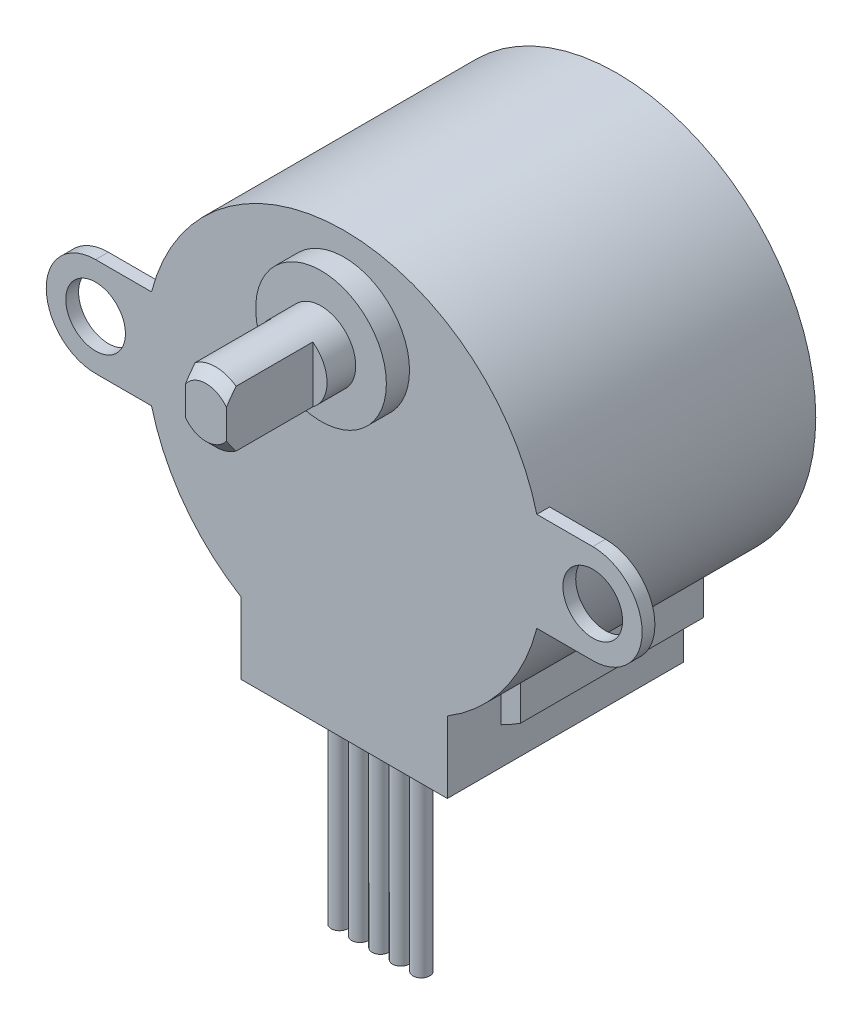
from build123d import *

# Parameters (mm, degrees)
SKETCH1_R           = 14
BOSS_EXTRUDE1_DEPTH = 19.2
BOSS_EXTRUDE2_DEPTH = 16.64
BOSS_EXTRUDE3_DEPTH = 12.87
SKETCH4_R           = 0.585
BOSS_EXTRUDE4_DEPTH = 14
SKETCH5_R           = 4.6
BOSS_EXTRUDE5_DEPTH = 1.63
SKETCH6_R           = 2.445
BOSS_EXTRUDE6_DEPTH = 8.1
CUT_EXTRUDE1_DEPTH  = 6.08
CHAMFER1_SIZE       = 0.68
SKETCH8_R           = 2.1
BOSS_EXTRUDE7_DEPTH = 0.9


with BuildPart() as part:
    # Sketch1 → Boss-Extrude1 (new body)
    with BuildSketch(Plane.XY):
        Circle(SKETCH1_R)
    extrude(amount=-BOSS_EXTRUDE1_DEPTH)

    # Sketch2 → Boss-Extrude2 (add)
    with BuildSketch(Plane.XY):
        with BuildLine():
            Line((-7.265, -11.967446469), (-7.265, -17))
            Line((-7.265, -17), (7.265, -17))
            Line((7.265, -17), (7.265, -11.967446469))
            ThreePointArc((7.265, -11.967446469), (0, -14), (-7.265, -11.967446469))
        make_face()
    extrude(amount=-BOSS_EXTRUDE2_DEPTH)

    # Sketch3 → Boss-Extrude3 (add)
    with BuildSketch(Plane(origin=(0, 0, -16.64), x_dir=(-1, 0, 0), z_dir=(0, 0, -1))):
        with BuildLine():
            Line((7.265, -14.390072098), (7.265, -11.967446469))
            ThreePointArc((7.265, -11.967446469), (7.969331726, -11.510419273), (8.645, -11.011992327))
            Line((8.645, -11.011992327), (8.645, -13.605821364))
            ThreePointArc((8.645, -13.605821364), (7.964658643, -14.014942479), (7.265, -14.390072098))
        make_face()
        with BuildLine():
            Line((-7.265, -11.967446469), (-7.265, -14.390072098))
            ThreePointArc((-7.265, -14.390072098), (-7.964658643, -14.014942479), (-8.645, -13.605821364))
            Line((-8.645, -13.605821364), (-8.645, -11.011992327))
            ThreePointArc((-8.645, -11.011992327), (-7.969331726, -11.510419273), (-7.265, -11.967446469))
        make_face()
    extrude(amount=-BOSS_EXTRUDE3_DEPTH)

    # Sketch4 → Boss-Extrude4 (add)
    with BuildSketch(Plane.XZ.offset(17)):
        with Locations((-2.88, -2.555)):
            Circle(SKETCH4_R)
        with Locations((-1.44, -2.555)):
            Circle(SKETCH4_R)
        with Locations((0, -2.555)):
            Circle(SKETCH4_R)
        with Locations((1.44, -2.555)):
            Circle(SKETCH4_R)
        with Locations((2.88, -2.555)):
            Circle(SKETCH4_R)
    extrude(amount=BOSS_EXTRUDE4_DEPTH)

    # Sketch5 → Boss-Extrude5 (add)
    with BuildSketch(Plane.XY):
        with Locations((0, 7.77)):
            Circle(SKETCH5_R)
    extrude(amount=BOSS_EXTRUDE5_DEPTH)

    # Sketch6 → Boss-Extrude6 (add)
    with BuildSketch(Plane.XY.offset(1.63)):
        with Locations((0, 7.77)):
            Circle(SKETCH6_R)
    extrude(amount=BOSS_EXTRUDE6_DEPTH)

    # Sketch7 → Cut-Extrude1 (cut)
    with BuildSketch(Plane.XY.offset(9.73)):
        with BuildLine():
            Line((1.44, 9.745961791), (1.44, 5.794038209))
            ThreePointArc((1.44, 5.794038209), (2.445, 7.77), (1.44, 9.745961791))
        make_face()
        with BuildLine():
            Line((-1.44, 9.745961791), (-1.44, 5.794038209))
            ThreePointArc((-1.44, 5.794038209), (-2.445, 7.77), (-1.44, 9.745961791))
        make_face()
    extrude(amount=-CUT_EXTRUDE1_DEPTH, mode=Mode.SUBTRACT)

    # Chamfer1
    chamfer1_edges = [part.edges().sort_by_distance(p)[0] for p in [
        (0, 10.215, 9.73),
        (0, 5.325, 9.73),
    ]]
    chamfer(chamfer1_edges, length=CHAMFER1_SIZE)

    # Sketch8 → Boss-Extrude7 (add)
    with BuildSketch(Plane.XY):
        with BuildLine():
            Line((-13.561872105, 3.475), (-17.5, 3.475))
            ThreePointArc((-17.5, 3.475), (-20.975, 0), (-17.5, -3.475))
            Line((-17.5, -3.475), (-13.561872105, -3.475))
            ThreePointArc((-13.561872105, -3.475), (-14, 0), (-13.561872105, 3.475))
        make_face()
        with Locations((-17.5, 0)):
            Circle(SKETCH8_R, mode=Mode.SUBTRACT)
        with BuildLine():
            Line((17.5, -3.475), (13.561872105, -3.475))
            ThreePointArc((13.561872105, -3.475), (14, 0), (13.561872105, 3.475))
            Line((13.561872105, 3.475), (17.5, 3.475))
            ThreePointArc((17.5, 3.475), (20.975, 0), (17.5, -3.475))
        make_face()
        with Locations((17.5, 0)):
            Circle(SKETCH8_R, mode=Mode.SUBTRACT)
    extrude(amount=-BOSS_EXTRUDE7_DEPTH)


solid = part.part
